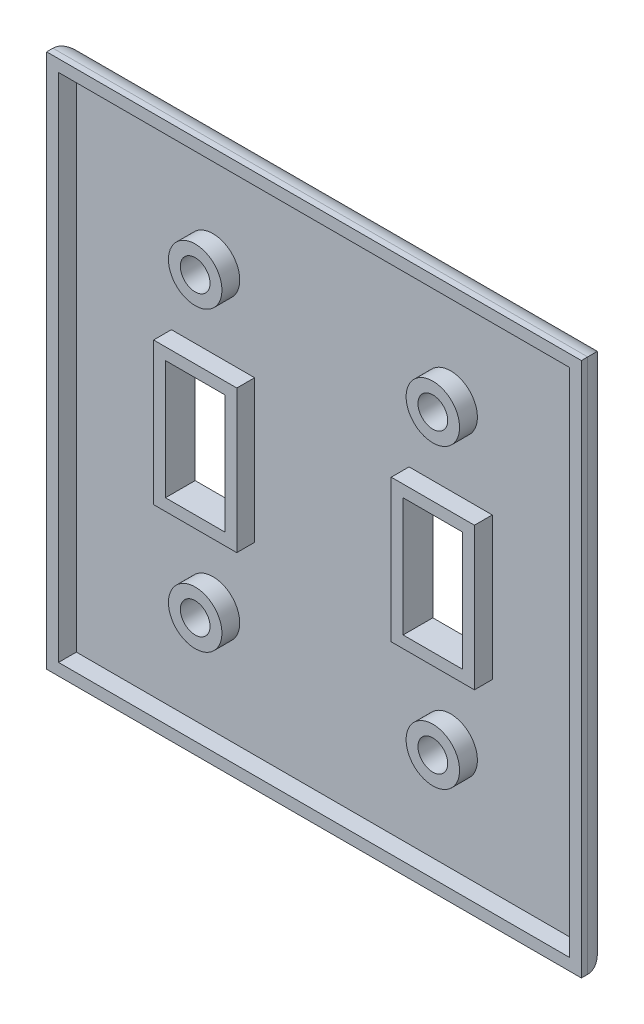
from build123d import *

# Parameters (mm, degrees)
SKETCH2_W           = 114.3
SKETCH2_H           = 114.3
BOSS_EXTRUDE1_DEPTH = 6.35
SKETCH3_R           = 3.175
CUT_EXTRUDE1_DEPTH  = 162.769287876
SKETCH3_3_R         = 3.175
CUT_EXTRUDE2_DEPTH  = 162.769287876
SKETCH3_4_R         = 3.175
CUT_EXTRUDE3_DEPTH  = 162.769287876
SKETCH3_5_W         = 12.7
SKETCH3_5_H         = 25.4
CUT_EXTRUDE4_DEPTH  = 162.769287876
SKETCH3_6_W         = 12.7
SKETCH3_6_H         = 25.4
CUT_EXTRUDE5_DEPTH  = 162.769287876
SKETCH3_7_R         = 3.175
CUT_EXTRUDE6_DEPTH  = 162.769287876
SHELL1_T            = -2.54
FILLET1_R           = 5


with BuildPart() as part:
    # Sketch2 → Boss-Extrude1 (new body)
    with BuildSketch(Plane.XY):
        with Locations((57.15, 57.15)):
            Rectangle(SKETCH2_W, SKETCH2_H)
    extrude(amount=BOSS_EXTRUDE1_DEPTH)

    # Sketch3 → Cut-Extrude1 (cut, through all)
    with BuildSketch(Plane.XY.offset(6.35)):
        with Locations((31.75, 88.9)):
            Circle(SKETCH3_R)
    extrude(amount=-CUT_EXTRUDE1_DEPTH, mode=Mode.SUBTRACT)

    # Sketch3_3 → Cut-Extrude2 (cut, through all)
    with BuildSketch(Plane.XY.offset(6.35)):
        with Locations((82.55, 88.9)):
            Circle(SKETCH3_3_R)
    extrude(amount=-CUT_EXTRUDE2_DEPTH, mode=Mode.SUBTRACT)

    # Sketch3_4 → Cut-Extrude3 (cut, through all)
    with BuildSketch(Plane.XY.offset(6.35)):
        with Locations((31.75, 25.4)):
            Circle(SKETCH3_4_R)
    extrude(amount=-CUT_EXTRUDE3_DEPTH, mode=Mode.SUBTRACT)

    # Sketch3_5 → Cut-Extrude4 (cut, through all)
    with BuildSketch(Plane.XY.offset(6.35)):
        with Locations((31.75, 57.15)):
            Rectangle(SKETCH3_5_W, SKETCH3_5_H)
    extrude(amount=-CUT_EXTRUDE4_DEPTH, mode=Mode.SUBTRACT)

    # Sketch3_6 → Cut-Extrude5 (cut, through all)
    with BuildSketch(Plane.XY.offset(6.35)):
        with Locations((82.55, 57.15)):
            Rectangle(SKETCH3_6_W, SKETCH3_6_H)
    extrude(amount=-CUT_EXTRUDE5_DEPTH, mode=Mode.SUBTRACT)

    # Sketch3_7 → Cut-Extrude6 (cut, through all)
    with BuildSketch(Plane.XY.offset(6.35)):
        with Locations((82.55, 25.4)):
            Circle(SKETCH3_7_R)
    extrude(amount=-CUT_EXTRUDE6_DEPTH, mode=Mode.SUBTRACT)

    # Shell1
    shell1_openings = [part.faces().sort_by_distance(p)[0] for p in [
        (57.15, 57.15, 6.35),
    ]]
    offset(amount=SHELL1_T, openings=shell1_openings, kind=Kind.INTERSECTION)

    # Fillet1
    fillet1_edges = [part.edges().sort_by_distance(p)[0] for p in [
        (0, 57.15, 0),
        (57.15, 0, 0),
        (114.3, 57.15, 0),
        (57.15, 114.3, 0),
    ]]
    fillet(fillet1_edges, radius=FILLET1_R)


solid = part.part
